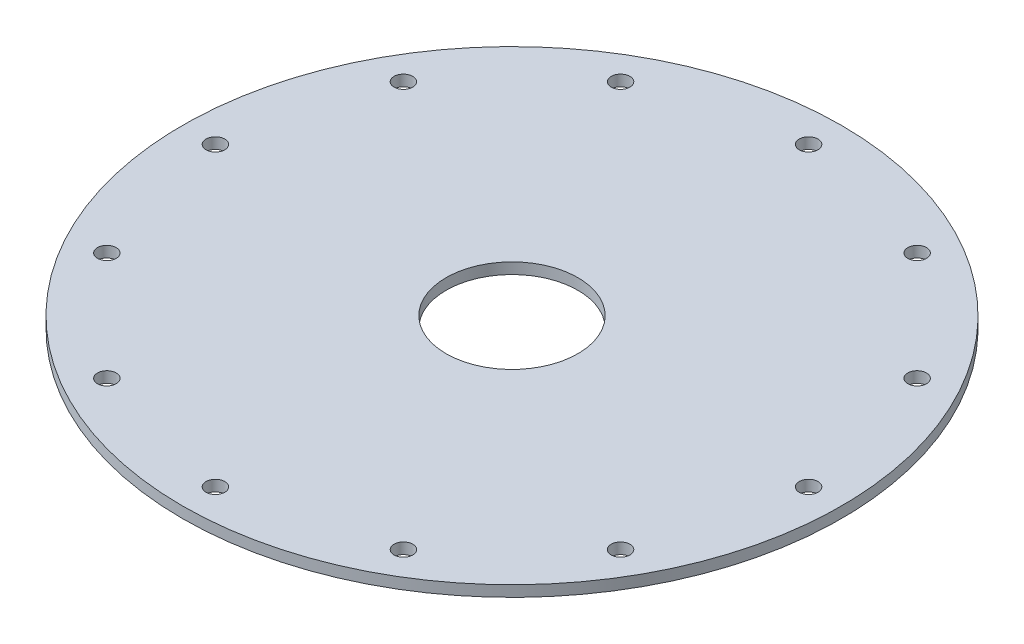
from build123d import *

# Parameters (mm, degrees)
SKETCH1_W                    = 38.1
SKETCH1_H                    = 1.5875
F_36_0_1065_DIAMETER_HOLE1_D = 2.7051
CIRPATTERN1_COUNT            = 12


with BuildPart() as part:
    # Sketch1 → Revolve1 (revolve)
    with BuildSketch(Plane.XY):
        with Locations((-28.575, 0.79375)):
            Rectangle(SKETCH1_W, SKETCH1_H)
    revolve(axis=Axis((0, 55, 0), (0, -1, 0)))

    # #36 (0.1065) Diameter Hole1 (through all)
    with Locations(Plane(origin=(0, 1.5875, 0), x_dir=(1, 0, 0), z_dir=(0, 1, 0))):
        with Locations((-42.8625, 0)):
            f_36_0_1065_diameter_hole1 = Hole(F_36_0_1065_DIAMETER_HOLE1_D / 2)

    # CirPattern1: #36 (0.1065) Diameter Hole1 ×12 about axis
    cirpattern1_axis = Axis((0, 0, 0), (0, 1, 0))
    for i in range(1, CIRPATTERN1_COUNT):
        add(f_36_0_1065_diameter_hole1.rotate(cirpattern1_axis, i * 360 / CIRPATTERN1_COUNT), mode=Mode.SUBTRACT)


solid = part.part
